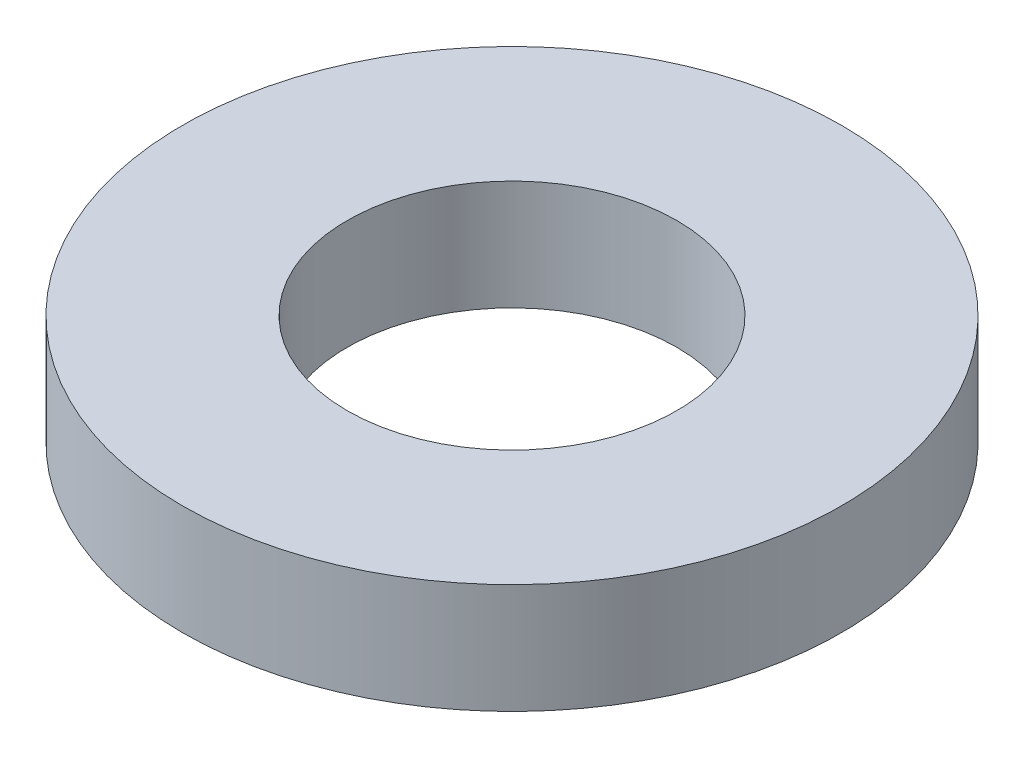
from build123d import *

# Parameters (mm, degrees)
SKETCH_1_R      = 3
SKETCH_1_R_2    = 1.5
EXTRUDE_1_DEPTH = 1


with BuildPart() as part:
    # 草图1 → 凸台-拉伸1 (new body)
    with BuildSketch(Plane(origin=(0, 0, 0), x_dir=(1, 0, 0), z_dir=(0, 1, 0))):
        Circle(SKETCH_1_R)
        Circle(SKETCH_1_R_2, mode=Mode.SUBTRACT)
    extrude(amount=EXTRUDE_1_DEPTH)


solid = part.part
